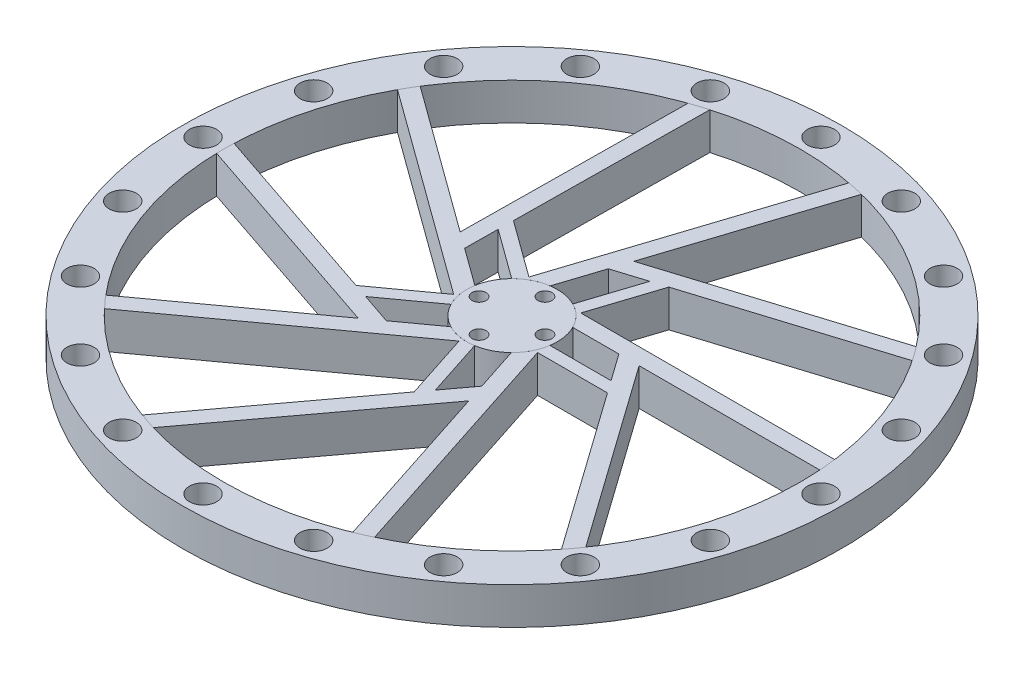
from build123d import *

# Parameters (mm, degrees)
SKETCH2_R                      = 80
SKETCH2_R_2                    = 70
BOSS_EXTRUDE2_DEPTH            = 9
SKETCH2_R_3                    = 11
BOSS_EXTRUDE2_2_DEPTH          = 9
BOSS_EXTRUDE5_START            = 4.5
BOSS_EXTRUDE5_DEPTH            = 4.5
M6_CLEARANCE_HOLE1_AT_2_COUNT  = 2
M6_CLEARANCE_HOLE1_AT_2_PITCH  = 23.465169756
M6_CLEARANCE_HOLE1_AT_3_COUNT  = 2
M6_CLEARANCE_HOLE1_AT_3_PITCH  = 46.352549156
M6_CLEARANCE_HOLE1_AT_4_COUNT  = 2
M6_CLEARANCE_HOLE1_AT_4_PITCH  = 68.098574961
M6_CLEARANCE_HOLE1_AT_5_COUNT  = 2
M6_CLEARANCE_HOLE1_AT_5_PITCH  = 88.167787844
M6_CLEARANCE_HOLE1_AT_6_COUNT  = 2
M6_CLEARANCE_HOLE1_AT_6_PITCH  = 106.066017178
M6_CLEARANCE_HOLE1_AT_7_COUNT  = 2
M6_CLEARANCE_HOLE1_AT_7_PITCH  = 121.352549156
M6_CLEARANCE_HOLE1_AT_8_COUNT  = 2
M6_CLEARANCE_HOLE1_AT_8_PITCH  = 133.650978628
M6_CLEARANCE_HOLE1_AT_9_COUNT  = 2
M6_CLEARANCE_HOLE1_AT_9_PITCH  = 142.658477444
M6_CLEARANCE_HOLE1_AT_10_COUNT = 2
M6_CLEARANCE_HOLE1_AT_10_PITCH = 148.153251089
M6_CLEARANCE_HOLE1_AT_11_COUNT = 2
M6_CLEARANCE_HOLE1_AT_11_PITCH = 150
M6_CLEARANCE_HOLE1_AT_12_COUNT = 2
M6_CLEARANCE_HOLE1_AT_12_PITCH = 148.153251089
M6_CLEARANCE_HOLE1_AT_13_COUNT = 2
M6_CLEARANCE_HOLE1_AT_13_PITCH = 142.658477444
M6_CLEARANCE_HOLE1_AT_14_COUNT = 2
M6_CLEARANCE_HOLE1_AT_14_PITCH = 133.650978628
M6_CLEARANCE_HOLE1_AT_15_COUNT = 2
M6_CLEARANCE_HOLE1_AT_15_PITCH = 121.352549156
M6_CLEARANCE_HOLE1_AT_16_COUNT = 2
M6_CLEARANCE_HOLE1_AT_16_PITCH = 106.066017178
M6_CLEARANCE_HOLE1_AT_17_COUNT = 2
M6_CLEARANCE_HOLE1_AT_17_PITCH = 88.167787844
M6_CLEARANCE_HOLE1_AT_18_COUNT = 2
M6_CLEARANCE_HOLE1_AT_18_PITCH = 68.098574961
M6_CLEARANCE_HOLE1_AT_19_COUNT = 2
M6_CLEARANCE_HOLE1_AT_19_PITCH = 46.352549156
M6_CLEARANCE_HOLE1_AT_20_COUNT = 2
M6_CLEARANCE_HOLE1_AT_20_PITCH = 23.465169756
M3_CLEARANCE_HOLE1_AT_2_COUNT  = 2
M3_CLEARANCE_HOLE1_AT_2_PITCH  = 11.313708499
M3_CLEARANCE_HOLE1_AT_3_COUNT  = 2
M3_CLEARANCE_HOLE1_AT_3_PITCH  = 16
M3_CLEARANCE_HOLE1_AT_4_COUNT  = 2
M3_CLEARANCE_HOLE1_AT_4_PITCH  = 11.313708499


with BuildPart() as part:
    # Sketch2 → Boss-Extrude2 (new body)
    with BuildSketch(Plane(origin=(0, 0, 0), x_dir=(1, 0, 0), z_dir=(0, 1, 0))):
        Circle(SKETCH2_R)
        Circle(SKETCH2_R_2, mode=Mode.SUBTRACT)
    extrude(amount=BOSS_EXTRUDE2_DEPTH)

    # Sketch6 → M6 Clearance Hole1 (revolve, cut)
    with BuildSketch(Plane(origin=(-23.176274578, 9, 71.329238722), x_dir=(0, 0, 1), z_dir=(1, 0, 0))):
        Polygon((0, 0), (0, 11.982840043), (3.3, 10), (3.3, 0), align=None)
    m6_clearance_hole1 = revolve(axis=Axis((-23.176274578, 15.35, 71.329238722), (0, -1, 0)), mode=Mode.SUBTRACT)

    # M6 Clearance Hole1 at 2: M6 Clearance Hole1 ×2
    with Locations(*[Vector(0.987688341, 0, 0.156434465) * (i * M6_CLEARANCE_HOLE1_AT_2_PITCH) for i in range(1, M6_CLEARANCE_HOLE1_AT_2_COUNT)]):
        add(m6_clearance_hole1, mode=Mode.SUBTRACT)

    # M6 Clearance Hole1 at 3: M6 Clearance Hole1 ×2
    with Locations(*[(i * M6_CLEARANCE_HOLE1_AT_3_PITCH, 0, 0) for i in range(1, M6_CLEARANCE_HOLE1_AT_3_COUNT)]):
        add(m6_clearance_hole1, mode=Mode.SUBTRACT)

    # M6 Clearance Hole1 at 4: M6 Clearance Hole1 ×2
    with Locations(*[Vector(0.987688341, 0, -0.156434465) * (i * M6_CLEARANCE_HOLE1_AT_4_PITCH) for i in range(1, M6_CLEARANCE_HOLE1_AT_4_COUNT)]):
        add(m6_clearance_hole1, mode=Mode.SUBTRACT)

    # M6 Clearance Hole1 at 5: M6 Clearance Hole1 ×2
    with Locations(*[Vector(0.951056516, 0, -0.309016994) * (i * M6_CLEARANCE_HOLE1_AT_5_PITCH) for i in range(1, M6_CLEARANCE_HOLE1_AT_5_COUNT)]):
        add(m6_clearance_hole1, mode=Mode.SUBTRACT)

    # M6 Clearance Hole1 at 6: M6 Clearance Hole1 ×2
    with Locations(*[Vector(0.891006524, 0, -0.4539905) * (i * M6_CLEARANCE_HOLE1_AT_6_PITCH) for i in range(1, M6_CLEARANCE_HOLE1_AT_6_COUNT)]):
        add(m6_clearance_hole1, mode=Mode.SUBTRACT)

    # M6 Clearance Hole1 at 7: M6 Clearance Hole1 ×2
    with Locations(*[Vector(0.809016994, 0, -0.587785252) * (i * M6_CLEARANCE_HOLE1_AT_7_PITCH) for i in range(1, M6_CLEARANCE_HOLE1_AT_7_COUNT)]):
        add(m6_clearance_hole1, mode=Mode.SUBTRACT)

    # M6 Clearance Hole1 at 8: M6 Clearance Hole1 ×2
    with Locations(*[Vector(0.707106781, 0, -0.707106781) * (i * M6_CLEARANCE_HOLE1_AT_8_PITCH) for i in range(1, M6_CLEARANCE_HOLE1_AT_8_COUNT)]):
        add(m6_clearance_hole1, mode=Mode.SUBTRACT)

    # M6 Clearance Hole1 at 9: M6 Clearance Hole1 ×2
    with Locations(*[Vector(0.587785252, 0, -0.809016994) * (i * M6_CLEARANCE_HOLE1_AT_9_PITCH) for i in range(1, M6_CLEARANCE_HOLE1_AT_9_COUNT)]):
        add(m6_clearance_hole1, mode=Mode.SUBTRACT)

    # M6 Clearance Hole1 at 10: M6 Clearance Hole1 ×2
    with Locations(*[Vector(0.4539905, 0, -0.891006524) * (i * M6_CLEARANCE_HOLE1_AT_10_PITCH) for i in range(1, M6_CLEARANCE_HOLE1_AT_10_COUNT)]):
        add(m6_clearance_hole1, mode=Mode.SUBTRACT)

    # M6 Clearance Hole1 at 11: M6 Clearance Hole1 ×2
    with Locations(*[Vector(0.309016994, 0, -0.951056516) * (i * M6_CLEARANCE_HOLE1_AT_11_PITCH) for i in range(1, M6_CLEARANCE_HOLE1_AT_11_COUNT)]):
        add(m6_clearance_hole1, mode=Mode.SUBTRACT)

    # M6 Clearance Hole1 at 12: M6 Clearance Hole1 ×2
    with Locations(*[Vector(0.156434465, 0, -0.987688341) * (i * M6_CLEARANCE_HOLE1_AT_12_PITCH) for i in range(1, M6_CLEARANCE_HOLE1_AT_12_COUNT)]):
        add(m6_clearance_hole1, mode=Mode.SUBTRACT)

    # M6 Clearance Hole1 at 13: M6 Clearance Hole1 ×2
    with Locations(*[(0, 0, -i * M6_CLEARANCE_HOLE1_AT_13_PITCH) for i in range(1, M6_CLEARANCE_HOLE1_AT_13_COUNT)]):
        add(m6_clearance_hole1, mode=Mode.SUBTRACT)

    # M6 Clearance Hole1 at 14: M6 Clearance Hole1 ×2
    with Locations(*[Vector(-0.156434465, 0, -0.987688341) * (i * M6_CLEARANCE_HOLE1_AT_14_PITCH) for i in range(1, M6_CLEARANCE_HOLE1_AT_14_COUNT)]):
        add(m6_clearance_hole1, mode=Mode.SUBTRACT)

    # M6 Clearance Hole1 at 15: M6 Clearance Hole1 ×2
    with Locations(*[Vector(-0.309016994, 0, -0.951056516) * (i * M6_CLEARANCE_HOLE1_AT_15_PITCH) for i in range(1, M6_CLEARANCE_HOLE1_AT_15_COUNT)]):
        add(m6_clearance_hole1, mode=Mode.SUBTRACT)

    # M6 Clearance Hole1 at 16: M6 Clearance Hole1 ×2
    with Locations(*[Vector(-0.4539905, 0, -0.891006524) * (i * M6_CLEARANCE_HOLE1_AT_16_PITCH) for i in range(1, M6_CLEARANCE_HOLE1_AT_16_COUNT)]):
        add(m6_clearance_hole1, mode=Mode.SUBTRACT)

    # M6 Clearance Hole1 at 17: M6 Clearance Hole1 ×2
    with Locations(*[Vector(-0.587785252, 0, -0.809016994) * (i * M6_CLEARANCE_HOLE1_AT_17_PITCH) for i in range(1, M6_CLEARANCE_HOLE1_AT_17_COUNT)]):
        add(m6_clearance_hole1, mode=Mode.SUBTRACT)

    # M6 Clearance Hole1 at 18: M6 Clearance Hole1 ×2
    with Locations(*[Vector(-0.707106781, 0, -0.707106781) * (i * M6_CLEARANCE_HOLE1_AT_18_PITCH) for i in range(1, M6_CLEARANCE_HOLE1_AT_18_COUNT)]):
        add(m6_clearance_hole1, mode=Mode.SUBTRACT)

    # M6 Clearance Hole1 at 19: M6 Clearance Hole1 ×2
    with Locations(*[Vector(-0.809016994, 0, -0.587785252) * (i * M6_CLEARANCE_HOLE1_AT_19_PITCH) for i in range(1, M6_CLEARANCE_HOLE1_AT_19_COUNT)]):
        add(m6_clearance_hole1, mode=Mode.SUBTRACT)

    # M6 Clearance Hole1 at 20: M6 Clearance Hole1 ×2
    with Locations(*[Vector(-0.891006524, 0, -0.4539905) * (i * M6_CLEARANCE_HOLE1_AT_20_PITCH) for i in range(1, M6_CLEARANCE_HOLE1_AT_20_COUNT)]):
        add(m6_clearance_hole1, mode=Mode.SUBTRACT)


with BuildPart() as body_2:
    # Sketch2 → Boss-Extrude2 2 (new body)
    with BuildSketch(Plane(origin=(0, 0, 0), x_dir=(1, 0, 0), z_dir=(0, 1, 0))):
        Circle(SKETCH2_R_3)
    extrude(amount=BOSS_EXTRUDE2_2_DEPTH)

    # Sketch7 → M3 Clearance Hole1 (revolve, cut)
    with BuildSketch(Plane(origin=(8, 9, 0), x_dir=(0, 0, 1), z_dir=(1, 0, 0))):
        Polygon((0, 0), (0, 11.021463052), (1.7, 10), (1.7, 0), align=None)
    m3_clearance_hole1 = revolve(axis=Axis((8, 15.35, 0), (0, -1, 0)), mode=Mode.SUBTRACT)

    # M3 Clearance Hole1 at 2: M3 Clearance Hole1 ×2
    with Locations(*[Vector(-0.707106781, 0, 0.707106781) * (i * M3_CLEARANCE_HOLE1_AT_2_PITCH) for i in range(1, M3_CLEARANCE_HOLE1_AT_2_COUNT)]):
        add(m3_clearance_hole1, mode=Mode.SUBTRACT)

    # M3 Clearance Hole1 at 3: M3 Clearance Hole1 ×2
    with Locations(*[(-i * M3_CLEARANCE_HOLE1_AT_3_PITCH, 0, 0) for i in range(1, M3_CLEARANCE_HOLE1_AT_3_COUNT)]):
        add(m3_clearance_hole1, mode=Mode.SUBTRACT)

    # M3 Clearance Hole1 at 4: M3 Clearance Hole1 ×2
    with Locations(*[Vector(-0.707106781, 0, -0.707106781) * (i * M3_CLEARANCE_HOLE1_AT_4_PITCH) for i in range(1, M3_CLEARANCE_HOLE1_AT_4_COUNT)]):
        add(m3_clearance_hole1, mode=Mode.SUBTRACT)


with BuildPart() as body_3:
    # Sketch3 → Boss-Extrude5 (new body, symmetric)
    with BuildSketch(Plane(origin=(0, 0, 0), x_dir=(1, 0, 0), z_dir=(0, 1, 0)).offset(BOSS_EXTRUDE5_START)):
        with BuildLine():
            Line((2.626229721, 23.936805944), (1.845026115, 21.532508467))
            Line((1.845026115, 21.532508467), (9.528643077, 23.935723237))
            Line((9.528643077, 23.935723237), (13.039859005, 25.033930764))
            Line((13.039859005, 25.033930764), (58.053299276, 39.112842433))
            ThreePointArc((58.053299276, 39.112842433), (56.849781729, 40.84240832), (55.594753028, 42.534967212))
            Line((55.594753028, 42.534967212), (3.360838219, 26.197698425))
            Line((3.360838219, 26.197698425), (2.626229721, 23.936805944))
        make_face()
        with BuildLine():
            Line((7.797362943, 8.899186938), (6.465637775, 8.899186938))
            ThreePointArc((6.465637775, 8.899186938), (8.398800493, 7.103530832), (9.848754609, 4.899186938))
            Line((9.848754609, 4.899186938), (21.048776914, 4.899186938))
            Line((21.048776914, 4.899186938), (25.954047924, 4.899186938))
            Line((25.954047924, 4.899186938), (69.828346446, 4.899186938))
            ThreePointArc((69.828346446, 4.899186938), (69.658897132, 6.902032338), (69.432013307, 8.899186938))
            Line((69.432013307, 8.899186938), (7.797362943, 8.899186938))
        make_face()
        with BuildLine():
            Line((25.954047924, 4.899186938), (21.048776914, 4.899186938))
            Line((21.048776914, 4.899186938), (25.708738201, -1.665732837))
            Line((25.708738201, -1.665732837), (27.838221018, -4.665732837))
            Line((27.838221018, -4.665732837), (55.137979722, -43.125435559))
            ThreePointArc((55.137979722, -43.125435559), (56.410987255, -41.446357101), (57.632881221, -39.729724415))
            Line((57.632881221, -39.729724415), (25.954047924, 4.899186938))
        make_face()
        with BuildLine():
            ThreePointArc((10.873147388, -1.665732837), (10.702537483, -2.540805273), (10.461621679, -3.399186938))
            Line((10.461621679, -3.399186938), (10.873147388, -4.665732837))
            Line((10.873147388, -4.665732837), (27.838221018, -4.665732837))
            Line((27.838221018, -4.665732837), (25.708738201, -1.665732837))
            Line((25.708738201, -1.665732837), (10.873147388, -1.665732837))
        make_face()
        with BuildLine():
            ThreePointArc((10.461621679, -3.399186938), (9.351231371, -5.79262219), (7.70283621, -7.852790226))
            Line((7.70283621, -7.852790226), (11.163833439, -18.504644422))
            Line((11.163833439, -18.504644422), (12.679645543, -23.16983438))
            Line((12.679645543, -23.16983438), (26.237549403, -64.896771887))
            ThreePointArc((26.237549403, -64.896771887), (28.090005854, -64.116702747), (29.919301793, -63.283768695))
            Line((29.919301793, -63.283768695), (10.873147388, -4.665732837))
            Line((10.873147388, -4.665732837), (10.461621679, -3.399186938))
        make_face()
        with BuildLine():
            Line((6.360230939, -24.965202746), (4.16510777, -27.917512239))
            Line((4.16510777, -27.917512239), (-23.976153736, -65.765827388))
            ThreePointArc((-23.976153736, -65.765827388), (-21.985874267, -66.457665718), (-19.975673564, -67.089287265))
            Line((-19.975673564, -67.089287265), (12.679645543, -23.16983438))
            Line((12.679645543, -23.16983438), (11.163833439, -18.504644422))
            Line((11.163833439, -18.504644422), (6.360230939, -24.965202746))
        make_face()
        with BuildLine():
            ThreePointArc((1.775781257, -10.85571743), (0.890816554, -10.963870022), (0, -11))
            Line((0, -11), (-1.077388292, -11.782768414))
            Line((-1.077388292, -11.782768414), (4.16510777, -27.917512239))
            Line((4.16510777, -27.917512239), (6.360230939, -24.965202746))
            Line((6.360230939, -24.965202746), (1.775781257, -10.85571743))
        make_face()
        with BuildLine():
            ThreePointArc((0, -11), (-2.619421669, -10.68356823), (-5.088140022, -9.752478204))
            Line((-5.088140022, -9.752478204), (-14.149148404, -16.335686141))
            Line((-14.149148404, -16.335686141), (-18.117596013, -19.218932099))
            Line((-18.117596013, -19.218932099), (-53.612649133, -45.007597724))
            ThreePointArc((-53.612649133, -45.007597724), (-52.29831877, -46.528333882), (-50.940867879, -48.010706928))
            Line((-50.940867879, -48.010706928), (-1.077388292, -11.782768414))
            Line((-1.077388292, -11.782768414), (0, -11))
        make_face()
        with BuildLine():
            Line((-21.777899304, -13.763610997), (-25.264042849, -12.588238609))
            Line((-25.264042849, -12.588238609), (-69.956057651, 2.479918935))
            ThreePointArc((-69.956057651, 2.479918935), (-69.999004824, 0.373260874), (-69.978526432, -1.733735395))
            Line((-69.978526432, -1.733735395), (-18.117596013, -19.218932099))
            Line((-18.117596013, -19.218932099), (-14.149148404, -16.335686141))
            Line((-14.149148404, -16.335686141), (-21.777899304, -13.763610997))
        make_face()
        with BuildLine():
            ThreePointArc((-9.775654215, -5.043469508), (-10.151982575, -4.235239049), (-10.461621679, -3.399186938))
            Line((-10.461621679, -3.399186938), (-11.539009972, -2.616418525))
            Line((-11.539009972, -2.616418525), (-25.264042849, -12.588238609))
            Line((-25.264042849, -12.588238609), (-21.777899304, -13.763610997))
            Line((-21.777899304, -13.763610997), (-9.775654215, -5.043469508))
        make_face()
        with BuildLine():
            Line((-11.539009972, -2.616418525), (-10.461621679, -3.399186938))
            ThreePointArc((-10.461621679, -3.399186938), (-10.970122993, -0.810186097), (-10.847479682, 1.825427221))
            Line((-10.847479682, 1.825427221), (-19.908488065, 8.408635158))
            Line((-19.908488065, 8.408635158), (-23.876935674, 11.291881116))
            Line((-23.876935674, 11.291881116), (-59.371988794, 37.080546741))
            ThreePointArc((-59.371988794, 37.080546741), (-60.412144408, 35.360610968), (-61.402489559, 33.61151999))
            Line((-61.402489559, 33.61151999), (-11.539009972, -2.616418525))
        make_face()
        with BuildLine():
            Line((-19.819712913, 16.458823342), (-7.817467824, 7.738681853))
            ThreePointArc((-7.817467824, 7.738681853), (-7.165086838, 8.346348339), (-6.465637775, 8.899186938))
            Line((-6.465637775, 8.899186938), (-6.054112067, 10.165732837))
            Line((-6.054112067, 10.165732837), (-19.779144944, 20.13755292))
            Line((-19.779144944, 20.13755292), (-19.819712913, 16.458823342))
        make_face()
        with BuildLine():
            Line((-23.876935674, 11.291881116), (-19.908488065, 8.408635158))
            Line((-19.908488065, 8.408635158), (-19.819712913, 16.458823342))
            Line((-19.819712913, 16.458823342), (-19.779144944, 20.13755292))
            Line((-19.779144944, 20.13755292), (-19.259067611, 67.298501579))
            ThreePointArc((-19.259067611, 67.298501579), (-21.275889893, 66.688353625), (-23.273434254, 66.017779863))
            Line((-23.273434254, 66.017779863), (-23.876935674, 11.291881116))
        make_face()
        with BuildLine():
            Line((-6.054112067, 10.165732837), (-6.465637775, 8.899186938))
            ThreePointArc((-6.465637775, 8.899186938), (-4.160487202, 10.182845685), (-1.615971114, 10.880654271))
            Line((-1.615971114, 10.880654271), (1.845026115, 21.532508467))
            Line((1.845026115, 21.532508467), (2.626229721, 23.936805944))
            Line((2.626229721, 23.936805944), (3.360838219, 26.197698425))
            Line((3.360838219, 26.197698425), (16.918742079, 67.924635932))
            ThreePointArc((16.918742079, 67.924635932), (14.961560192, 68.382393323), (12.992042338, 68.783768695))
            Line((12.992042338, 68.783768695), (-6.054112067, 10.165732837))
        make_face()
        with BuildLine():
            Line((9.528643077, 23.935723237), (4.944193394, 9.826237921))
            ThreePointArc((4.944193394, 9.826237921), (5.723715376, 9.393566005), (6.465637775, 8.899186938))
            Line((6.465637775, 8.899186938), (7.797362943, 8.899186938))
            Line((7.797362943, 8.899186938), (13.039859005, 25.033930764))
            Line((13.039859005, 25.033930764), (9.528643077, 23.935723237))
        make_face()
    extrude(amount=BOSS_EXTRUDE5_DEPTH, both=True)


solid = Compound([part.part, body_2.part, body_3.part])
